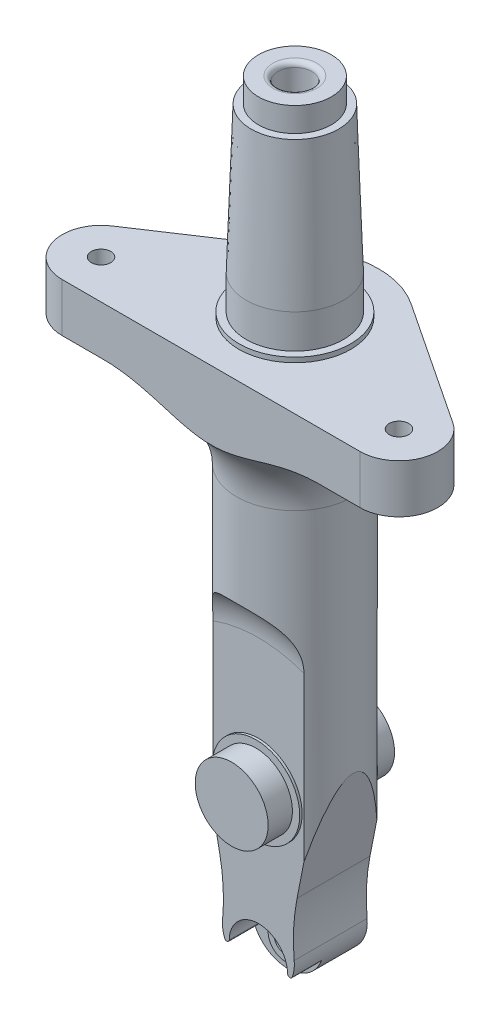
from build123d import *

# Parameters (mm, degrees)
SKETCH1_W               = 12
SKETCH1_H               = 88.272317903
SKETCH2_W               = 4.5
SKETCH2_H               = 60
CUT_EXTRUDE1_DEPTH      = 13
CUT_EXTRUDE1_DEPTH_BACK = 13
CUT_EXTRUDE2_DEPTH      = 5.5
CUT_EXTRUDE2_DEPTH_BACK = 20.5
SKETCH12_R              = 7.393886086
BOSS_EXTRUDE4_DEPTH     = 15
FILLET2_R               = 40
SKETCH4_R               = 6
CUT_EXTRUDE3_DEPTH      = 6
SKETCH5_R               = 2.25
CUT_EXTRUDE4_DEPTH      = 14.5
SKETCH6_R               = 7.5
BOSS_EXTRUDE1_DEPTH     = 13
SKETCH9_R               = 3.5
SKETCH10_R              = 9
BOSS_EXTRUDE2_DEPTH     = 8
SKETCH11_R              = 3.5
SKETCH11_R_2            = 2.25
BOSS_EXTRUDE3_DEPTH     = 0.5
FILLET1_R               = 0.5
SKETCH13_R              = 12
SKETCH13_R_2            = 3.5
BOSS_EXTRUDE5_DEPTH     = 17
FILLET3_R               = 16
SKETCH16_R              = 77.650275013
CUT_EXTRUDE5_DEPTH      = 22
SKETCH17_R              = 2
CUT_EXTRUDE6_DEPTH      = 22
CUT_EXTRUDE7_START      = -132.272318
SKETCH20_R              = 3.5
CUT_EXTRUDE7_DEPTH      = 132.272318
FILLET5_R               = 1


with BuildPart() as part:
    # Sketch1 → Revolve1 (revolve)
    with BuildSketch(Plane(origin=(0, 0, 0), x_dir=(0, 0, -1), z_dir=(1, 0, 0))):
        with Locations((-6, 44.136158952)):
            Rectangle(SKETCH1_W, SKETCH1_H)
    revolve(axis=Axis((0, 88.272317903, 0), (0, -1, 0)))

    # Sketch2 → Cut-Extrude1 (cut, two sides)
    with BuildSketch(Plane(origin=(0, 0, 0), x_dir=(0, 0, -1), z_dir=(1, 0, 0))) as cut_extrude1_sk:
        with Locations((-9.75, 30)):
            Rectangle(SKETCH2_W, SKETCH2_H)
        with Locations((9.75, 30)):
            Rectangle(SKETCH2_W, SKETCH2_H)
    extrude(amount=CUT_EXTRUDE1_DEPTH, mode=Mode.SUBTRACT)
    extrude(cut_extrude1_sk.sketch, amount=-CUT_EXTRUDE1_DEPTH_BACK, mode=Mode.SUBTRACT)

    # Sketch3 → Cut-Extrude2 (cut, two sides)
    with BuildSketch(Plane.XY.offset(7.5)) as cut_extrude2_sk:
        with BuildLine():
            Line((-12, 40), (-4.905482814, 4.032405892))
            ThreePointArc((-4.905482814, 4.032405892), (0, 0), (4.905482814, 4.032405892))
            Line((4.905482814, 4.032405892), (12, 40))
            Line((12, 40), (12, 0))
            Line((12, 0), (12, -1))
            Line((12, -1), (-12, -1))
            Line((-12, -1), (-12, 0))
            Line((-12, 0), (-12, 40))
        make_face()
    extrude(amount=CUT_EXTRUDE2_DEPTH, mode=Mode.SUBTRACT)
    extrude(cut_extrude2_sk.sketch, amount=-CUT_EXTRUDE2_DEPTH_BACK, mode=Mode.SUBTRACT)

    # Sketch12 → Boss-Extrude4 (add)
    with BuildSketch(Plane.XY.offset(7.5)):
        with Locations((0, 7.393886086)):
            Circle(SKETCH12_R)
    extrude(amount=-BOSS_EXTRUDE4_DEPTH)

    # Fillet2
    fillet2_edges = [part.edges().sort_by_distance(p)[0] for p in [
        (6.324137111, 11.224661628, 0),
        (-6.324137111, 11.224661628, 0),
    ]]
    fillet(fillet2_edges, radius=FILLET2_R)

    # Sketch4 → Cut-Extrude3 (cut)
    with BuildSketch(Plane.XY.offset(7.5)):
        with Locations((0, 5)):
            Circle(SKETCH4_R)
    extrude(amount=-CUT_EXTRUDE3_DEPTH, mode=Mode.SUBTRACT)

    # Sketch5 → Cut-Extrude4 (cut, through all)
    with BuildSketch(Plane.XY.offset(1.5)):
        with Locations((0, 5)):
            Circle(SKETCH5_R)
    extrude(amount=-CUT_EXTRUDE4_DEPTH, mode=Mode.SUBTRACT)

    # Sketch6 → Boss-Extrude1 (add, symmetric)
    with BuildSketch(Plane.XY):
        with Locations((0, 35)):
            Circle(SKETCH6_R)
    extrude(amount=BOSS_EXTRUDE1_DEPTH, both=True)

    # Sketch7 → Cut-Revolve1 (revolve, cut)
    with BuildSketch(Plane(origin=(0, 0, 0), x_dir=(0, 0, -1), z_dir=(1, 0, 0))):
        with BuildLine():
            Line((-7.5, 61.927405715), (-7.5, 51.927405715))
            Line((-7.5, 51.927405715), (-17.5, 51.927405715))
            ThreePointArc((-17.5, 51.927405715), (-24.571067812, 68.998473527), (-7.5, 61.927405715))
        make_face()
        with BuildLine():
            Line((7.5, 51.927405715), (17.5, 51.927405715))
            ThreePointArc((17.5, 51.927405715), (24.571067812, 68.998473527), (7.5, 61.927405715))
            Line((7.5, 61.927405715), (7.5, 51.927405715))
        make_face()
    revolve(axis=Axis((0, 35, 13), (0, 0, -1)), mode=Mode.SUBTRACT)

    # Cut-Sweep1: sweep along a path in Sketch8
    with BuildLine(Plane(origin=(0, 0, 0), x_dir=(0, 0, -1), z_dir=(1, 0, 0))) as cut_sweep1_path:
        Line((0, 88.272317903), (0, 25.420292636))
        ThreePointArc((0, 25.420292636), (3.646414893, 15.617430543), (12.812814028, 10.580608761))
    # Sketch9 → Cut-Sweep1 (sweep, cut)
    with BuildSketch(Plane(origin=(0, 88.272317903, 0), x_dir=(1, 0, 0), z_dir=(0, 1, 0))):
        Circle(SKETCH9_R)
    sweep(path=cut_sweep1_path.line, mode=Mode.SUBTRACT)

    # Sketch10 → Boss-Extrude2 (add, symmetric)
    with BuildSketch(Plane.XY):
        with Locations((0, 35)):
            Circle(SKETCH10_R)
    extrude(amount=BOSS_EXTRUDE2_DEPTH, both=True)

    # Sketch11 → Boss-Extrude3 (add)
    with BuildSketch(Plane.XY.offset(1.5)):
        with Locations((0, 5)):
            Circle(SKETCH11_R)
        with Locations((0, 5)):
            Circle(SKETCH11_R_2, mode=Mode.SUBTRACT)
    extrude(amount=BOSS_EXTRUDE3_DEPTH)

    # Fillet1
    fillet1_edges = [part.edges().sort_by_distance(p)[0] for p in [
        (-5.356920685, 2.297519515, 4.5),
        (5.356920685, 2.297519515, 4.5),
    ]]
    fillet(fillet1_edges, radius=FILLET1_R)

    # Sketch13 → Boss-Extrude5 (add)
    with BuildSketch(Plane(origin=(0, 88.272317903, 0), x_dir=(1, 0, 0), z_dir=(0, 1, 0))):
        Circle(SKETCH13_R)
        Circle(SKETCH13_R_2, mode=Mode.SUBTRACT)
    extrude(amount=BOSS_EXTRUDE5_DEPTH)

    # Sketch15 → Revolve2 (revolve)
    with BuildSketch(Plane(origin=(0, 0, 0), x_dir=(0, 0, -1), z_dir=(1, 0, 0))):
        Polygon((0, 105.272317903), (-40, 105.272317903), (-40, 115.272317903), (-11.5, 115.272317903), (-11.5, 116.272317903), (-10, 116.272317903), (-10, 123.272317903), (0, 123.272317903), align=None)
    revolve(axis=Axis((0, 88.826005803, 0), (0, -1, 0)))

    # Fillet3
    fillet3_edges = [part.edges().sort_by_distance(p)[0] for p in [
        (-12, 105.272317903, 0),
    ]]
    fillet(fillet3_edges, radius=FILLET3_R)

    # Sketch16 → Cut-Extrude5 (cut)
    with BuildSketch(Plane(origin=(0, 115.272317903, 0), x_dir=(1, 0, 0), z_dir=(0, 1, 0))):
        Circle(SKETCH16_R)
        with BuildLine():
            Line((-30.638590038, -17.23454387), (30.638590038, -17.23454387))
            ThreePointArc((30.638590038, -17.23454387), (38.298237548, -11.543179837), (35.059424473, -2.566993877))
            Line((35.059424473, -2.566993877), (9.523883126, 14.364022856))
            ThreePointArc((9.523883126, 14.364022856), (0, 17.23454387), (-9.523883126, 14.364022856))
            Line((-9.523883126, 14.364022856), (-35.059424473, -2.566993877))
            ThreePointArc((-35.059424473, -2.566993877), (-38.298237548, -11.543179837), (-30.638590038, -17.23454387))
        make_face(mode=Mode.SUBTRACT)
    extrude(amount=-CUT_EXTRUDE5_DEPTH, mode=Mode.SUBTRACT)

    # Sketch17 → Cut-Extrude6 (cut)
    with BuildSketch(Plane(origin=(0, 115.272317903, 0), x_dir=(1, 0, 0), z_dir=(0, 1, 0))):
        with Locations((-30.638590038, -9.23454387)):
            Circle(SKETCH17_R)
        with Locations((30.638590038, -9.23454387)):
            Circle(SKETCH17_R)
    extrude(amount=-CUT_EXTRUDE6_DEPTH, mode=Mode.SUBTRACT)

    # Sketch19 → Revolve3 (revolve)
    with BuildSketch(Plane.XY):
        Polygon((-10, 123.272317903), (-9, 153.272317903), (-7.5, 153.272317903), (-7.5, 158.272317903), (0, 158.272317903), (0, 123.272317903), align=None)
    revolve(axis=Axis((0, 123.272317903, 0), (0, 1, 0)))

    # Sketch20 → Cut-Extrude7 (cut)
    with BuildSketch(Plane(origin=(0, 158.272317903, 0), x_dir=(1, 0, 0), z_dir=(0, 1, 0)).offset(CUT_EXTRUDE7_START)):
        Circle(SKETCH20_R)
    extrude(amount=CUT_EXTRUDE7_DEPTH, mode=Mode.SUBTRACT)

    # Fillet5
    fillet5_edges = [part.edges().sort_by_distance(p)[0] for p in [
        (-3.5, 158.272317903, 0),
    ]]
    fillet(fillet5_edges, radius=FILLET5_R)


solid = part.part
